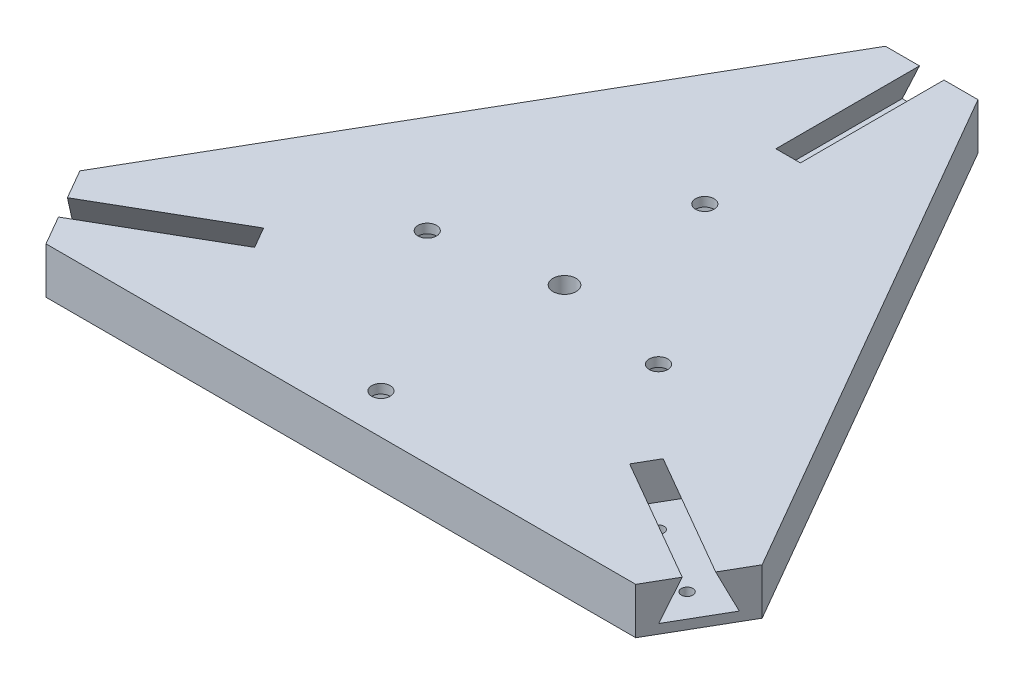
from build123d import *

# Parameters (mm, degrees)
ESQUISSE1_R                  = 2.5
BOSS_EXTRU_1_DEPTH           = 5
ESQUISSE2_R                  = 1.25
ENL_V_MAT_EXTRU_1_DEPTH      = 11
R_P_TITION_CIRCULAIRE1_COUNT = 3
ESQUISSE4_R                  = 2
ENL_V_MAT_EXTRU_3_DEPTH      = 11
ESQUISSE5_W                  = 60.3
ESQUISSE5_H                  = 80.3
ESQUISSE5_W_2                = 39.7
ESQUISSE5_H_2                = 59.7
ENL_V_MAT_EXTRU_4_DEPTH      = 8
ESQUISSE6_R                  = 6.325
ESQUISSE6_R_2                = 3.325
BOSS_EXTRU_2_DEPTH           = 10
ENL_V_MAT_EXTRU_5_DEPTH      = 31.04
R_P_TITION_CIRCULAIRE2_COUNT = 3


with BuildPart() as part:
    # Esquisse1 → Boss.-Extru.1 (new body, symmetric)
    with BuildSketch(Plane(origin=(0, 0, 0), x_dir=(1, 0, 0), z_dir=(0, 1, 0))):
        Polygon((-10, 79.372539332), (10, 79.372539332), (73.738635424, -31.026015628), (63.738635424, -48.346523704), (-63.738635424, -48.346523704), (-73.738635424, -31.026015628), align=None)
        Circle(ESQUISSE1_R, mode=Mode.SUBTRACT)
    extrude(amount=BOSS_EXTRU_1_DEPTH, both=True)

    # Esquisse2 → Enlèv. mat.-Extru.1 (cut, through all)
    with BuildSketch(Plane(origin=(0, 5, 0), x_dir=(1, 0, 0), z_dir=(0, 1, 0))):
        with Locations((-62.685117852, -36.191269666)):
            Circle(ESQUISSE2_R)
        with Locations((-47.910724463, -27.661269666)):
            Circle(ESQUISSE2_R)
    enl_v_mat_extru_1 = extrude(amount=-ENL_V_MAT_EXTRU_1_DEPTH, mode=Mode.SUBTRACT)

    # Répétition circulaire1: Enlèv. mat.-Extru.1 ×3 about axis
    r_p_tition_circulaire1_axis = Axis((0, 0, 0), (0, 1, 0))
    for i in range(1, R_P_TITION_CIRCULAIRE1_COUNT):
        add(enl_v_mat_extru_1.rotate(r_p_tition_circulaire1_axis, i * 360 / R_P_TITION_CIRCULAIRE1_COUNT), mode=Mode.SUBTRACT)

    # Esquisse4 → Enlèv. mat.-Extru.3 (cut, through all)
    with BuildSketch(Plane.XZ.offset(5)):
        with Locations((0, -30.32)):
            Circle(ESQUISSE4_R)
        with Locations((0, 39.68)):
            Circle(ESQUISSE4_R)
        with Locations((25, 4.68)):
            Circle(ESQUISSE4_R)
        with Locations((-25, 4.68)):
            Circle(ESQUISSE4_R)
    extrude(amount=-ENL_V_MAT_EXTRU_3_DEPTH, mode=Mode.SUBTRACT)

    # Esquisse5 → Enlèv. mat.-Extru.4 (cut)
    with BuildSketch(Plane.XZ.offset(5)):
        with Locations((0, 4.68)):
            Rectangle(ESQUISSE5_W, ESQUISSE5_H)
        with Locations((0, 4.68)):
            Rectangle(ESQUISSE5_W_2, ESQUISSE5_H_2, mode=Mode.SUBTRACT)
    extrude(amount=-ENL_V_MAT_EXTRU_4_DEPTH, mode=Mode.SUBTRACT)

    # Esquisse6 → Boss.-Extru.2 (add)
    with BuildSketch(Plane.XZ.offset(5)):
        with Locations((0, 20.18)):
            Circle(ESQUISSE6_R)
        with Locations((0, 20.18)):
            Circle(ESQUISSE6_R_2, mode=Mode.SUBTRACT)
    extrude(amount=BOSS_EXTRU_2_DEPTH)

    # Esquisse7 → Enlèv. mat.-Extru.5 (cut)
    with BuildSketch(Plane(origin=(-68.738635424, 0, 39.686269666), x_dir=(0.5, 0, 0.866025404), z_dir=(-0.866025404, 0, 0.5))):
        Polygon((-2.65, 5), (-6.38, -3), (6.38, -3), (2.65, 5), align=None)
    enl_v_mat_extru_5 = extrude(amount=-ENL_V_MAT_EXTRU_5_DEPTH, mode=Mode.SUBTRACT)

    # Répétition circulaire2: Enlèv. mat.-Extru.5 ×3 about axis
    r_p_tition_circulaire2_axis = Axis((0, 0, 0), (0, 1, 0))
    for i in range(1, R_P_TITION_CIRCULAIRE2_COUNT):
        add(enl_v_mat_extru_5.rotate(r_p_tition_circulaire2_axis, i * 360 / R_P_TITION_CIRCULAIRE2_COUNT), mode=Mode.SUBTRACT)


solid = part.part
